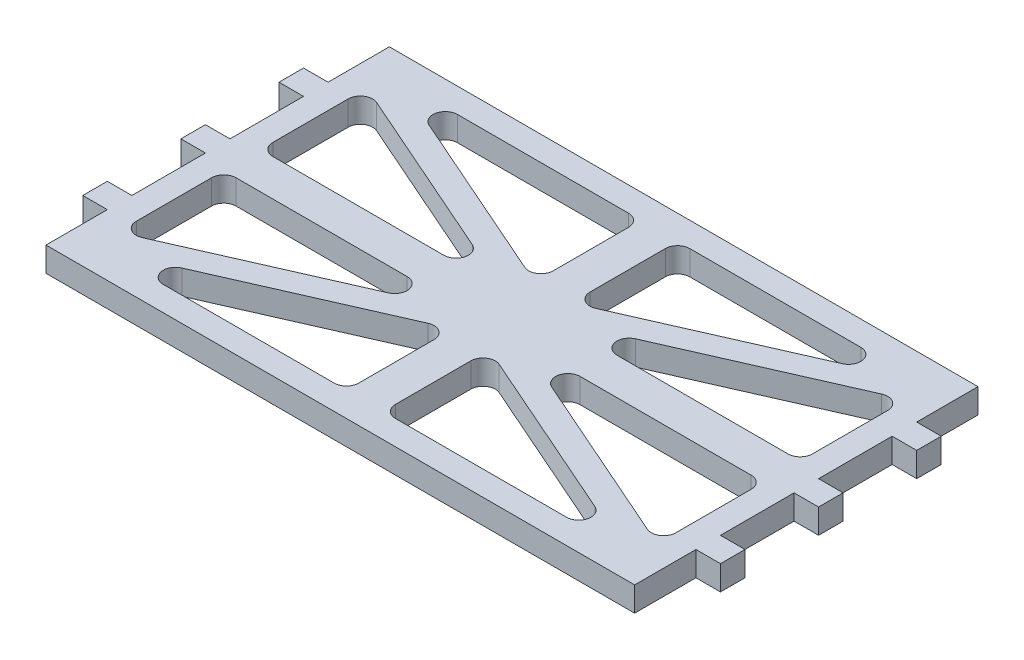
from build123d import *

# Parameters (mm, degrees)
BOSS_EXTRUDE1_DEPTH = 4
CUT_EXTRUDE1_DEPTH  = 10


with BuildPart() as part:
    # Sketch1 → Boss-Extrude1 (new body)
    with BuildSketch(Plane(origin=(0, 0, 0), x_dir=(1, 0, 0), z_dir=(0, 1, 0))):
        Polygon((-17.714285714, -42), (-17.714285714, -32), (-21.714285714, -32), (-21.714285714, -28), (-17.714285714, -28), (-17.714285714, -16), (-21.714285714, -16), (-21.714285714, -12), (-17.714285714, -12), (-17.714285714, 0), (-21.714285714, 0), (-21.714285714, 4), (-17.714285714, 4), (-17.714285714, 14), (78.285714286, 14), (78.285714286, 4), (82.285714286, 4), (82.285714286, 0), (78.285714286, 0), (78.285714286, -12), (82.285714286, -12), (82.285714286, -16), (78.285714286, -16), (78.285714286, -28), (82.285714286, -28), (82.285714286, -32), (78.285714286, -32), (78.285714286, -42), align=None)
    extrude(amount=-BOSS_EXTRUDE1_DEPTH)

    # Sketch2 → Cut-Extrude1 (cut)
    with BuildSketch(Plane(origin=(0, 0, 0), x_dir=(1, 0, 0), z_dir=(0, 1, 0))):
        with BuildLine():
            Line((-2.595319649, 10), (25.285714286, 10))
            ThreePointArc((25.285714286, 10), (26.699927848, 9.414213562), (27.285714286, 8))
            Line((27.285714286, 8), (27.285714286, -4.273399853))
            ThreePointArc((27.285714286, -4.273399853), (26.378511973, -5.948450065), (24.479921071, -6.103890851))
            Line((24.479921071, -6.103890851), (-3.401112863, 6.169509001))
            ThreePointArc((-3.401112863, 6.169509001), (-4.552483668, 8.411714709), (-2.595319649, 10))
        make_face()
        with BuildLine():
            ThreePointArc((-13.714285714, 3.273399853), (-12.807083402, 4.948450065), (-10.9084925, 5.103890851))
            Line((-10.9084925, 5.103890851), (16.972541435, -7.169509001))
            ThreePointArc((16.972541435, -7.169509001), (18.12391224, -9.411714709), (16.16674822, -11))
            Line((16.16674822, -11), (-11.714285714, -11))
            ThreePointArc((-11.714285714, -11), (-13.128499277, -10.414213562), (-13.714285714, -9))
            Line((-13.714285714, -9), (-13.714285714, 3.273399853))
        make_face()
        with BuildLine():
            Line((33.285714286, 8), (33.285714286, -4.273399853))
            ThreePointArc((33.285714286, -4.273399853), (34.192916598, -5.948450065), (36.0915075, -6.103890851))
            Line((36.0915075, -6.103890851), (63.972541435, 6.169509001))
            ThreePointArc((63.972541435, 6.169509001), (65.12391224, 8.411714709), (63.16674822, 10))
            Line((63.16674822, 10), (35.285714286, 10))
            ThreePointArc((35.285714286, 10), (33.871500723, 9.414213562), (33.285714286, 8))
        make_face()
        with BuildLine():
            ThreePointArc((74.285714286, -9), (73.699927848, -10.414213562), (72.285714286, -11))
            Line((72.285714286, -11), (44.404680351, -11))
            ThreePointArc((44.404680351, -11), (42.447516332, -9.411714709), (43.598887137, -7.169509001))
            Line((43.598887137, -7.169509001), (71.479921071, 5.103890851))
            ThreePointArc((71.479921071, 5.103890851), (73.378511973, 4.948450065), (74.285714286, 3.273399853))
            Line((74.285714286, 3.273399853), (74.285714286, -9))
        make_face()
        with BuildLine():
            ThreePointArc((74.285714286, -31.273399853), (73.378511973, -32.948450065), (71.479921071, -33.103890851))
            Line((71.479921071, -33.103890851), (43.598887137, -20.830490999))
            ThreePointArc((43.598887137, -20.830490999), (42.447516332, -18.588285291), (44.404680351, -17))
            Line((44.404680351, -17), (72.285714286, -17))
            ThreePointArc((72.285714286, -17), (73.699927848, -17.585786438), (74.285714286, -19))
            Line((74.285714286, -19), (74.285714286, -31.273399853))
        make_face()
        with BuildLine():
            Line((63.16674822, -38), (35.285714286, -38))
            ThreePointArc((35.285714286, -38), (33.871500723, -37.414213562), (33.285714286, -36))
            Line((33.285714286, -36), (33.285714286, -23.726600147))
            ThreePointArc((33.285714286, -23.726600147), (34.192916598, -22.051549935), (36.0915075, -21.896109149))
            Line((36.0915075, -21.896109149), (63.972541435, -34.169509001))
            ThreePointArc((63.972541435, -34.169509001), (65.12391224, -36.411714709), (63.16674822, -38))
        make_face()
        with BuildLine():
            Line((27.285714286, -36), (27.285714286, -23.726600147))
            ThreePointArc((27.285714286, -23.726600147), (26.378511973, -22.051549935), (24.479921071, -21.896109149))
            Line((24.479921071, -21.896109149), (-3.401112863, -34.169509001))
            ThreePointArc((-3.401112863, -34.169509001), (-4.552483668, -36.411714709), (-2.595319649, -38))
            Line((-2.595319649, -38), (25.285714286, -38))
            ThreePointArc((25.285714286, -38), (26.699927848, -37.414213562), (27.285714286, -36))
        make_face()
        with BuildLine():
            ThreePointArc((-13.714285714, -19), (-13.128499277, -17.585786438), (-11.714285714, -17))
            Line((-11.714285714, -17), (16.16674822, -17))
            ThreePointArc((16.16674822, -17), (18.12391224, -18.588285291), (16.972541435, -20.830490999))
            Line((16.972541435, -20.830490999), (-10.9084925, -33.103890851))
            ThreePointArc((-10.9084925, -33.103890851), (-12.807083402, -32.948450065), (-13.714285714, -31.273399853))
            Line((-13.714285714, -31.273399853), (-13.714285714, -19))
        make_face()
    extrude(amount=-CUT_EXTRUDE1_DEPTH, mode=Mode.SUBTRACT)


solid = part.part
